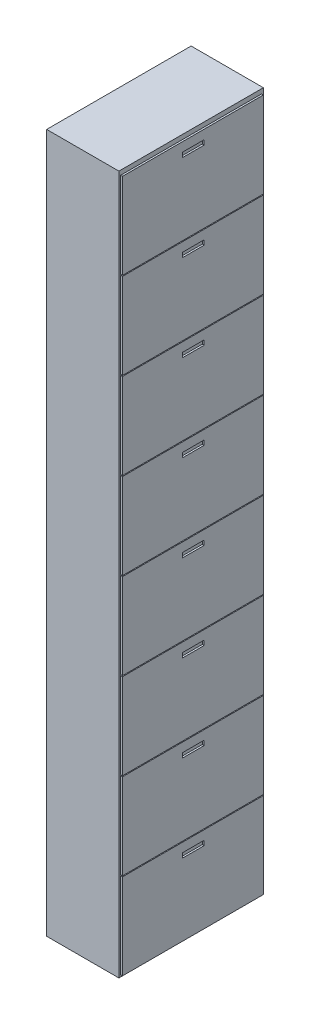
from build123d import *

# Parameters (mm, degrees)
SKETCH1_W           = 400
SKETCH1_H           = 3870
BOSS_EXTRUDE1_DEPTH = 800
SKETCH3_W           = 780
SKETCH3_H           = 475
SKETCH3_W_2         = 121.072841775
SKETCH3_H_2         = 25.802408903
BOSS_EXTRUDE3_DEPTH = 10


with BuildPart() as part:
    # Sketch1 → Boss-Extrude1 (new body)
    with BuildSketch(Plane.XY):
        with Locations((63.061970043, 2244.986327315)):
            Rectangle(SKETCH1_W, SKETCH1_H)
    extrude(amount=BOSS_EXTRUDE1_DEPTH)

    # Sketch3 → Boss-Extrude3 (add)
    with BuildSketch(Plane(origin=(263.061970043, 0, 0), x_dir=(0, 0, -1), z_dir=(1, 0, 0))):
        with Locations((-400, 557.486327315)):
            Rectangle(SKETCH3_W, SKETCH3_H)
        with Locations((-398.45909699, 731.583605055)):
            Rectangle(SKETCH3_W_2, SKETCH3_H_2, mode=Mode.SUBTRACT)
        with Locations((-400, 1037.486327315)):
            Rectangle(SKETCH3_W, SKETCH3_H)
        with Locations((-398.45909699, 1211.583605055)):
            Rectangle(SKETCH3_W_2, SKETCH3_H_2, mode=Mode.SUBTRACT)
        with Locations((-400, 1517.486327315)):
            Rectangle(SKETCH3_W, SKETCH3_H)
        with Locations((-398.45909699, 1691.583605055)):
            Rectangle(SKETCH3_W_2, SKETCH3_H_2, mode=Mode.SUBTRACT)
        with Locations((-400, 1997.486327315)):
            Rectangle(SKETCH3_W, SKETCH3_H)
        with Locations((-398.45909699, 2171.583605055)):
            Rectangle(SKETCH3_W_2, SKETCH3_H_2, mode=Mode.SUBTRACT)
        with Locations((-400, 2477.486327315)):
            Rectangle(SKETCH3_W, SKETCH3_H)
        with Locations((-398.45909699, 2651.583605055)):
            Rectangle(SKETCH3_W_2, SKETCH3_H_2, mode=Mode.SUBTRACT)
        with Locations((-400, 2957.486327315)):
            Rectangle(SKETCH3_W, SKETCH3_H)
        with Locations((-398.45909699, 3131.583605055)):
            Rectangle(SKETCH3_W_2, SKETCH3_H_2, mode=Mode.SUBTRACT)
        with Locations((-400, 3437.486327315)):
            Rectangle(SKETCH3_W, SKETCH3_H)
        with Locations((-398.45909699, 3611.583605055)):
            Rectangle(SKETCH3_W_2, SKETCH3_H_2, mode=Mode.SUBTRACT)
        with Locations((-400, 3917.486327315)):
            Rectangle(SKETCH3_W, SKETCH3_H)
        with Locations((-398.45909699, 4091.583605055)):
            Rectangle(SKETCH3_W_2, SKETCH3_H_2, mode=Mode.SUBTRACT)
    extrude(amount=BOSS_EXTRUDE3_DEPTH)


solid = part.part
